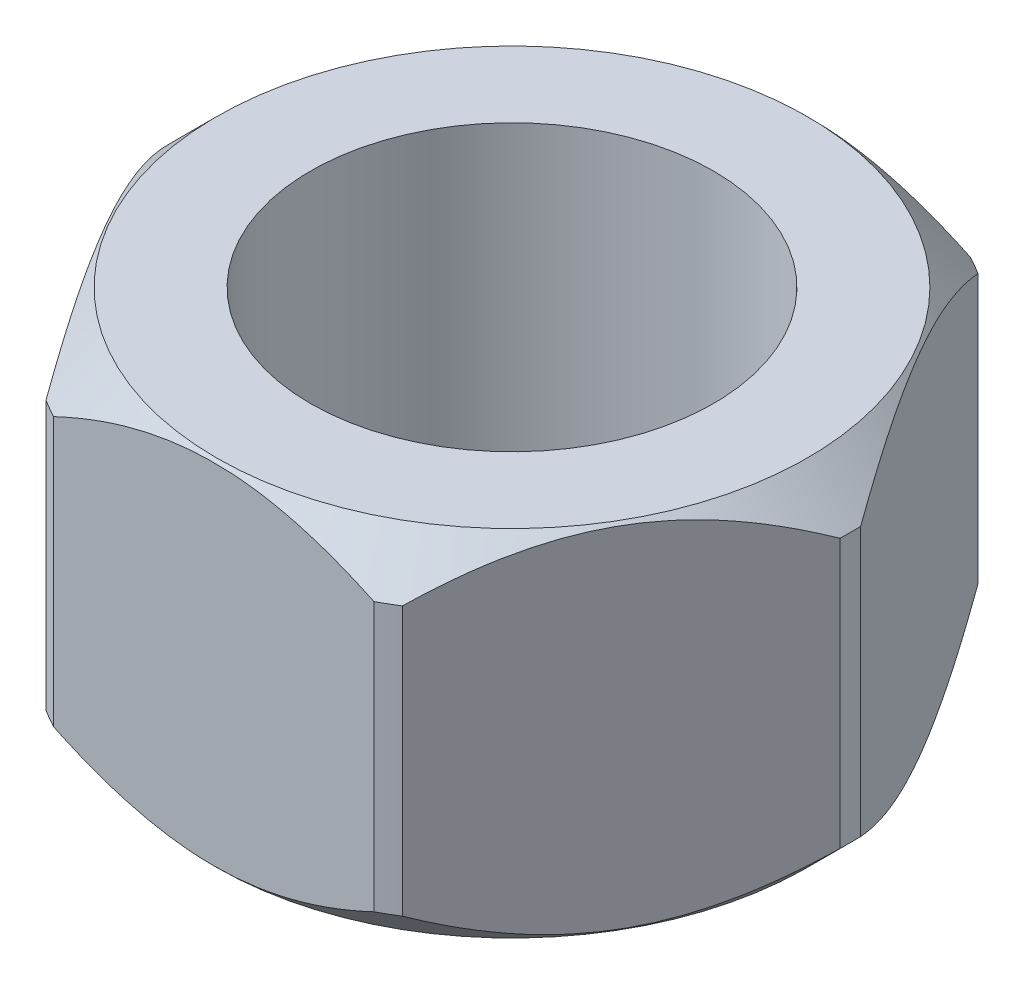
from build123d import *

# Parameters (mm, degrees)
SKETCH2_R      = 8.001
EXTRUDE2_DEPTH = 8.382
CHAMFER1_SIZE  = 1.016
EXTRUDE3_REACH = 10.382
SKETCH1_R      = 4.7625


with BuildPart() as part:
    # Sketch2 → Extrude2 (new body)
    with BuildSketch(Plane(origin=(0, 0, 0), x_dir=(1, 0, 0), z_dir=(0, 1, 0))):
        Circle(SKETCH2_R)
    extrude(amount=EXTRUDE2_DEPTH)

    # Chamfer1
    chamfer1_edges = [part.edges().sort_by_distance(p)[0] for p in [
        (-8.001, 0, 0),
        (-8.001, 8.382, 0),
    ]]
    chamfer(chamfer1_edges, length=CHAMFER1_SIZE)

    # Sketch1 → Extrude3 (cut, up to next)
    with BuildSketch(Plane(origin=(0, 0, 0), x_dir=(1, 0, 0), z_dir=(0, 1, 0)), mode=Mode.PRIVATE) as extrude3_sk1:
        with BuildLine():
            ThreePointArc((-8.138906745, 0), (-7.0485, -4.069453372), (-4.069453372, -7.0485))
            Line((-4.069453372, -7.0485), (-8.138906745, 0))
        make_face()
    extrude3_tool1 = extrude(extrude3_sk1.sketch, amount=EXTRUDE3_REACH, mode=Mode.PRIVATE) & part.part
    add(extrude3_tool1.solids().sort_by_distance((-6.484164, 0, 3.743634))[0], mode=Mode.SUBTRACT)
    # Sketch1 → Extrude3 (cut, up to next)
    with BuildSketch(Plane(origin=(0, 0, 0), x_dir=(1, 0, 0), z_dir=(0, 1, 0)), mode=Mode.PRIVATE) as extrude3_sk2:
        with BuildLine():
            ThreePointArc((-4.069453372, 7.0485), (-7.0485, 4.069453372), (-8.138906745, 0))
            Line((-8.138906745, 0), (-4.069453372, 7.0485))
        make_face()
    extrude3_tool2 = extrude(extrude3_sk2.sketch, amount=EXTRUDE3_REACH, mode=Mode.PRIVATE) & part.part
    add(extrude3_tool2.solids().sort_by_distance((-6.484164, 0, -3.743634))[0], mode=Mode.SUBTRACT)
    # Sketch1 → Extrude3 (cut, up to next)
    with BuildSketch(Plane(origin=(0, 0, 0), x_dir=(1, 0, 0), z_dir=(0, 1, 0)), mode=Mode.PRIVATE) as extrude3_sk3:
        Circle(SKETCH1_R)
    extrude3_tool3 = extrude(extrude3_sk3.sketch, amount=EXTRUDE3_REACH, mode=Mode.PRIVATE) & part.part
    add(extrude3_tool3.solids().sort_by_distance((0, 0, 0))[0], mode=Mode.SUBTRACT)
    # Sketch1 → Extrude3 (cut, up to next)
    with BuildSketch(Plane(origin=(0, 0, 0), x_dir=(1, 0, 0), z_dir=(0, 1, 0)), mode=Mode.PRIVATE) as extrude3_sk4:
        with BuildLine():
            Line((-4.069453372, 7.0485), (4.069453372, 7.0485))
            ThreePointArc((4.069453372, 7.0485), (0, 8.138906745), (-4.069453372, 7.0485))
        make_face()
    extrude3_tool4 = extrude(extrude3_sk4.sketch, amount=EXTRUDE3_REACH, mode=Mode.PRIVATE) & part.part
    add(extrude3_tool4.solids().sort_by_distance((0, 0, -7.487268))[0], mode=Mode.SUBTRACT)
    # Sketch1 → Extrude3 (cut, up to next)
    with BuildSketch(Plane(origin=(0, 0, 0), x_dir=(1, 0, 0), z_dir=(0, 1, 0)), mode=Mode.PRIVATE) as extrude3_sk5:
        with BuildLine():
            Line((4.069453372, 7.0485), (8.138906745, 0))
            ThreePointArc((8.138906745, 0), (7.0485, 4.069453372), (4.069453372, 7.0485))
        make_face()
    extrude3_tool5 = extrude(extrude3_sk5.sketch, amount=EXTRUDE3_REACH, mode=Mode.PRIVATE) & part.part
    add(extrude3_tool5.solids().sort_by_distance((6.484164, 0, -3.743634))[0], mode=Mode.SUBTRACT)
    # Sketch1 → Extrude3 (cut, up to next)
    with BuildSketch(Plane(origin=(0, 0, 0), x_dir=(1, 0, 0), z_dir=(0, 1, 0)), mode=Mode.PRIVATE) as extrude3_sk6:
        with BuildLine():
            Line((8.138906745, 0), (4.069453372, -7.0485))
            ThreePointArc((4.069453372, -7.0485), (7.0485, -4.069453372), (8.138906745, 0))
        make_face()
    extrude3_tool6 = extrude(extrude3_sk6.sketch, amount=EXTRUDE3_REACH, mode=Mode.PRIVATE) & part.part
    add(extrude3_tool6.solids().sort_by_distance((6.484164, 0, 3.743634))[0], mode=Mode.SUBTRACT)
    # Sketch1 → Extrude3 (cut, up to next)
    with BuildSketch(Plane(origin=(0, 0, 0), x_dir=(1, 0, 0), z_dir=(0, 1, 0)), mode=Mode.PRIVATE) as extrude3_sk7:
        with BuildLine():
            ThreePointArc((-4.069453372, -7.0485), (0, -8.138906745), (4.069453372, -7.0485))
            Line((4.069453372, -7.0485), (-4.069453372, -7.0485))
        make_face()
    extrude3_tool7 = extrude(extrude3_sk7.sketch, amount=EXTRUDE3_REACH, mode=Mode.PRIVATE) & part.part
    add(extrude3_tool7.solids().sort_by_distance((0, 0, 7.487268))[0], mode=Mode.SUBTRACT)


solid = part.part
